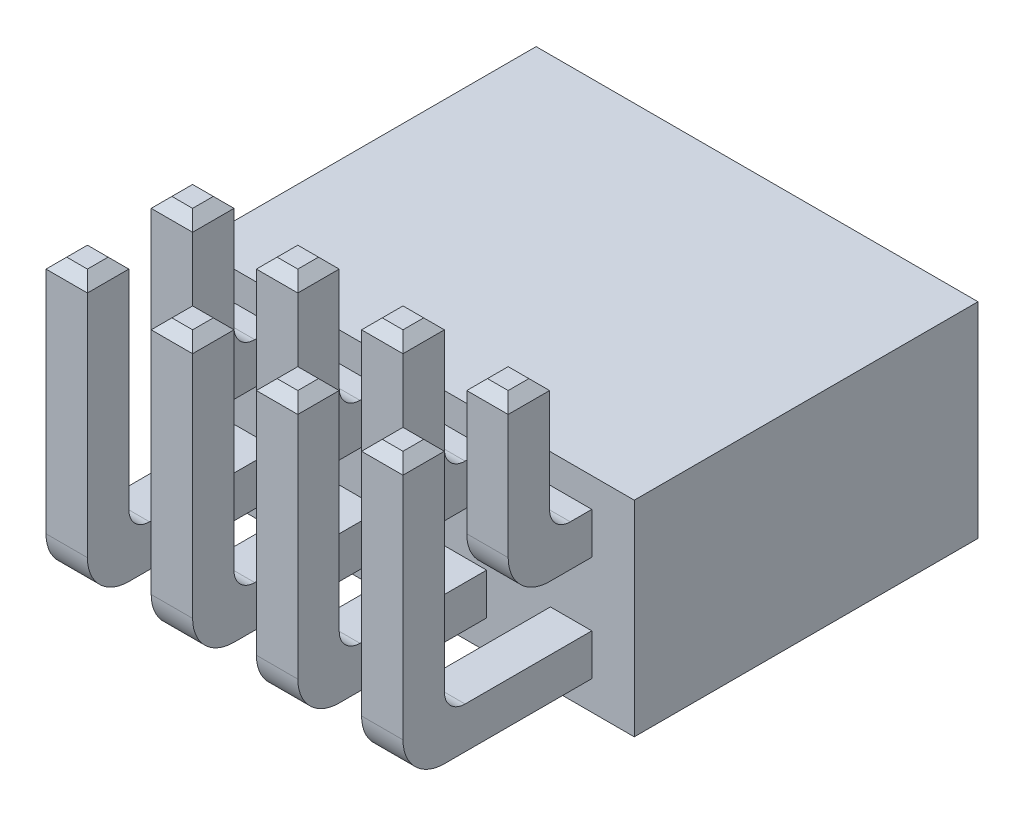
from build123d import *

# Parameters (mm, degrees)
SKETCH1_W           = 10.67
SKETCH1_H           = 4.95
BOSS_EXTRUDE1_DEPTH = 8.3
SKETCH3_W           = 1.382324252
SKETCH3_H           = 1.382324252
CUT_EXTRUDE1_DEPTH  = 3
BOSS_EXTRUDE2_START = 3.31
BOSS_EXTRUDE2_DEPTH = 1
LPATTERN1_COUNT     = 4
LPATTERN1_PITCH     = 2.54
CHAMFER1_SIZE       = 0.25


with BuildPart() as part:
    # Sketch1 → Boss-Extrude1 (new body)
    with BuildSketch(Plane.XY):
        Rectangle(SKETCH1_W, SKETCH1_H)
    extrude(amount=BOSS_EXTRUDE1_DEPTH)

    # Sketch3 → Cut-Extrude1 (cut)
    with BuildSketch(Plane(origin=(0, 0, 0), x_dir=(-1, 0, 0), z_dir=(0, 0, -1))):
        with Locations((-1.27, 1.27)):
            Rectangle(SKETCH3_W, SKETCH3_H)
        with Locations((-3.81, 1.27)):
            Rectangle(SKETCH3_W, SKETCH3_H)
        with Locations((1.27, 1.27)):
            Rectangle(SKETCH3_W, SKETCH3_H)
        with Locations((3.81, 1.27)):
            Rectangle(SKETCH3_W, SKETCH3_H)
        with Locations((-1.27, -1.27)):
            Rectangle(SKETCH3_W, SKETCH3_H)
        with Locations((1.27, -1.27)):
            Rectangle(SKETCH3_W, SKETCH3_H)
        with Locations((3.81, -1.27)):
            Rectangle(SKETCH3_W, SKETCH3_H)
        with Locations((-3.81, -1.27)):
            Rectangle(SKETCH3_W, SKETCH3_H)
    extrude(amount=-CUT_EXTRUDE1_DEPTH, mode=Mode.SUBTRACT)

    # Sketch4 → Boss-Extrude2 (add)
    with BuildSketch(Plane(origin=(0, 0, 0), x_dir=(0, 0, -1), z_dir=(1, 0, 0)).offset(BOSS_EXTRUDE2_START)):
        with BuildLine():
            Line((-8.3, 0.77), (-9.32, 0.77))
            ThreePointArc((-9.32, 0.77), (-10.027106781, 1.062893219), (-10.32, 1.77))
            Line((-10.32, 1.77), (-10.32, 5.015))
            Line((-10.32, 5.015), (-9.32, 5.015))
            Line((-9.32, 5.015), (-9.32, 2.27))
            ThreePointArc((-9.32, 2.27), (-9.173553391, 1.916446609), (-8.82, 1.77))
            Line((-8.82, 1.77), (-8.3, 1.77))
            Line((-8.3, 1.77), (-8.3, 0.77))
        make_face()
        with BuildLine():
            Line((-8.3, -1.77), (-11.86, -1.77))
            ThreePointArc((-11.86, -1.77), (-12.567106781, -1.477106781), (-12.86, -0.77))
            Line((-12.86, -0.77), (-12.86, 5.015))
            Line((-12.86, 5.015), (-11.86, 5.015))
            Line((-11.86, 5.015), (-11.86, -0.27))
            ThreePointArc((-11.86, -0.27), (-11.713553391, -0.623553391), (-11.36, -0.77))
            Line((-11.36, -0.77), (-8.3, -0.77))
            Line((-8.3, -0.77), (-8.3, -1.77))
        make_face()
    boss_extrude2 = extrude(amount=BOSS_EXTRUDE2_DEPTH)

    # LPattern1: Boss-Extrude2 ×4
    with Locations(*[(-i * LPATTERN1_PITCH, 0, 0) for i in range(1, LPATTERN1_COUNT)]):
        add(boss_extrude2)

    # Chamfer1
    chamfer1_edges = [part.edges().sort_by_distance(p)[0] for p in [
        (3.31, 5.015, 9.82),
        (3.81, 5.015, 9.32),
        (3.81, 5.015, 10.32),
        (4.31, 5.015, 9.82),
        (3.31, 5.015, 12.36),
        (3.81, 5.015, 11.86),
        (3.81, 5.015, 12.86),
        (4.31, 5.015, 12.36),
        (0.77, 5.015, 9.82),
        (1.27, 5.015, 9.32),
        (1.27, 5.015, 10.32),
        (1.77, 5.015, 9.82),
        (0.77, 5.015, 12.36),
        (1.27, 5.015, 11.86),
        (1.27, 5.015, 12.86),
        (1.77, 5.015, 12.36),
        (-1.77, 5.015, 9.82),
        (-1.27, 5.015, 9.32),
        (-1.27, 5.015, 10.32),
        (-0.77, 5.015, 9.82),
        (-1.77, 5.015, 12.36),
        (-1.27, 5.015, 11.86),
        (-1.27, 5.015, 12.86),
        (-0.77, 5.015, 12.36),
        (-4.31, 5.015, 9.82),
        (-3.81, 5.015, 9.32),
        (-3.81, 5.015, 10.32),
        (-3.31, 5.015, 9.82),
        (-4.31, 5.015, 12.36),
        (-3.81, 5.015, 11.86),
        (-3.81, 5.015, 12.86),
        (-3.31, 5.015, 12.36),
    ]]
    chamfer(chamfer1_edges, length=CHAMFER1_SIZE)


solid = part.part
